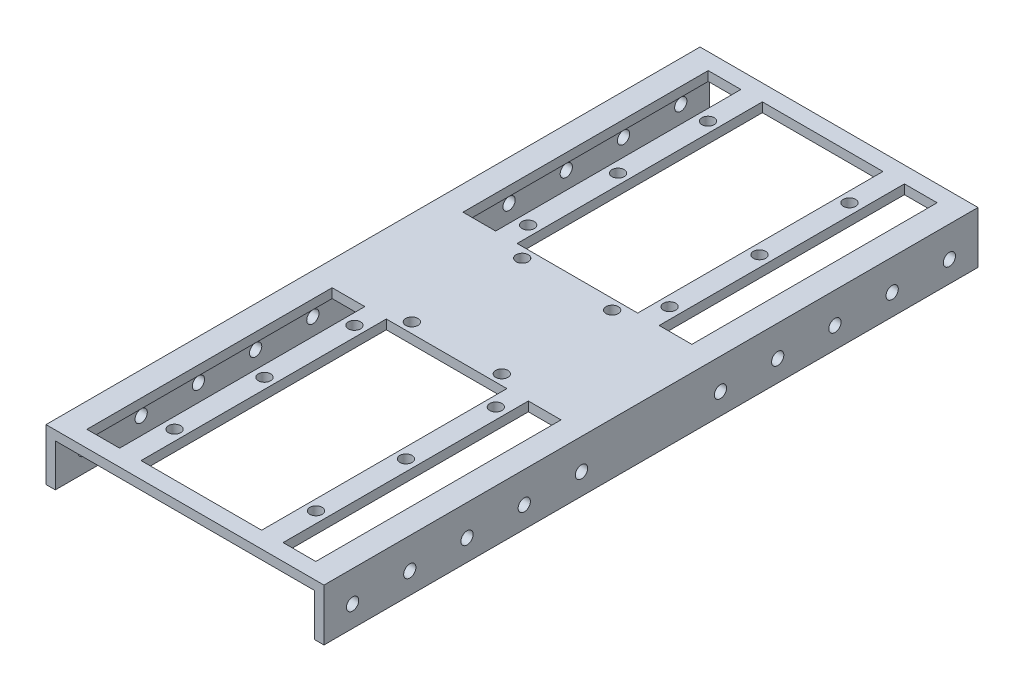
from build123d import *

# Parameters (mm, degrees)
BOSS_EXTRUDE1_DEPTH   = 80
SKETCH2_W             = 8
SKETCH2_H             = 60
SKETCH2_W_2           = 29.5
CUT_EXTRUDE1_DEPTH    = 160
SKETCH3_R             = 1.5
CUT_EXTRUDE2_DEPTH    = 160
F_3_0MM_DOWEL_HOLE1_D = 3
LPATTERN1_COUNT       = 5
LPATTERN1_PITCH       = 14
F_3_0MM_DOWEL_HOLE2_D = 3
LPATTERN2_COUNT       = 5
LPATTERN2_PITCH       = 14


with BuildPart() as part:
    # Sketch1 → Boss-Extrude1 (new body, symmetric)
    with BuildSketch(Plane.XY):
        Polygon((-34, 17.981191673), (34, 17.981191673), (34, 5.281191673), (31.715, 5.281191673), (31.715, 15.681191673), (-31.715, 15.681191673), (-31.715, 5.281191673), (-34, 5.281191673), align=None)
    extrude(amount=BOSS_EXTRUDE1_DEPTH, both=True)

    # Sketch2 → Cut-Extrude1 (cut)
    with BuildSketch(Plane(origin=(0, 17.981191673, 0), x_dir=(1, 0, 0), z_dir=(0, 1, 0))):
        with Locations((-24, 46)):
            Rectangle(SKETCH2_W, SKETCH2_H)
        with Locations((0, 46)):
            Rectangle(SKETCH2_W_2, SKETCH2_H)
        with Locations((24, 46)):
            Rectangle(SKETCH2_W, SKETCH2_H)
        with Locations((24, -46)):
            Rectangle(SKETCH2_W, SKETCH2_H)
        with Locations((0, -46)):
            Rectangle(SKETCH2_W_2, SKETCH2_H)
        with Locations((-24, -46)):
            Rectangle(SKETCH2_W, SKETCH2_H)
    extrude(amount=-CUT_EXTRUDE1_DEPTH, mode=Mode.SUBTRACT)

    # Sketch3 → Cut-Extrude2 (cut)
    with BuildSketch(Plane(origin=(0, 17.981191673, 0), x_dir=(1, 0, 0), z_dir=(0, 1, 0))):
        with Locations((-17.3, 65.25)):
            Circle(SKETCH3_R)
        with Locations((-11, 13.5)):
            Circle(SKETCH3_R)
        with Locations((17.3, 65.25)):
            Circle(SKETCH3_R)
        with Locations((17.3, 43.25)):
            Circle(SKETCH3_R)
        with Locations((17.3, 21.25)):
            Circle(SKETCH3_R)
        with Locations((-17.3, 43.25)):
            Circle(SKETCH3_R)
        with Locations((-17.3, 21.25)):
            Circle(SKETCH3_R)
        with Locations((11, 13.5)):
            Circle(SKETCH3_R)
        with Locations((17.3, -65.25)):
            Circle(SKETCH3_R)
        with Locations((17.3, -43.25)):
            Circle(SKETCH3_R)
        with Locations((17.3, -21.25)):
            Circle(SKETCH3_R)
        with Locations((11, -13.5)):
            Circle(SKETCH3_R)
        with Locations((-11, -13.5)):
            Circle(SKETCH3_R)
        with Locations((-17.3, -21.25)):
            Circle(SKETCH3_R)
        with Locations((-17.3, -43.25)):
            Circle(SKETCH3_R)
        with Locations((-17.3, -65.25)):
            Circle(SKETCH3_R)
    extrude(amount=-CUT_EXTRUDE2_DEPTH, mode=Mode.SUBTRACT)

    # Ø3.0mm Dowel Hole1 (through all)
    with Locations(Plane(origin=(-34, 10.481191673, -73), x_dir=(0, 0, -1), z_dir=(-1, 0, 0))):
        with Locations((0, 0)):
            f_3_0mm_dowel_hole1 = Hole(F_3_0MM_DOWEL_HOLE1_D / 2)

    # LPattern1: Ø3.0mm Dowel Hole1 ×5
    with Locations(*[(0, 0, i * LPATTERN1_PITCH) for i in range(1, LPATTERN1_COUNT)]):
        add(f_3_0mm_dowel_hole1, mode=Mode.SUBTRACT)

    # Ø3.0mm Dowel Hole2 (through all)
    with Locations(Plane(origin=(-34, 10.481191673, 73), x_dir=(0, 0, -1), z_dir=(-1, 0, 0))):
        with Locations((0, 0)):
            f_3_0mm_dowel_hole2 = Hole(F_3_0MM_DOWEL_HOLE2_D / 2)

    # LPattern2: Ø3.0mm Dowel Hole2 ×5
    with Locations(*[(0, 0, -i * LPATTERN2_PITCH) for i in range(1, LPATTERN2_COUNT)]):
        add(f_3_0mm_dowel_hole2, mode=Mode.SUBTRACT)


solid = part.part
